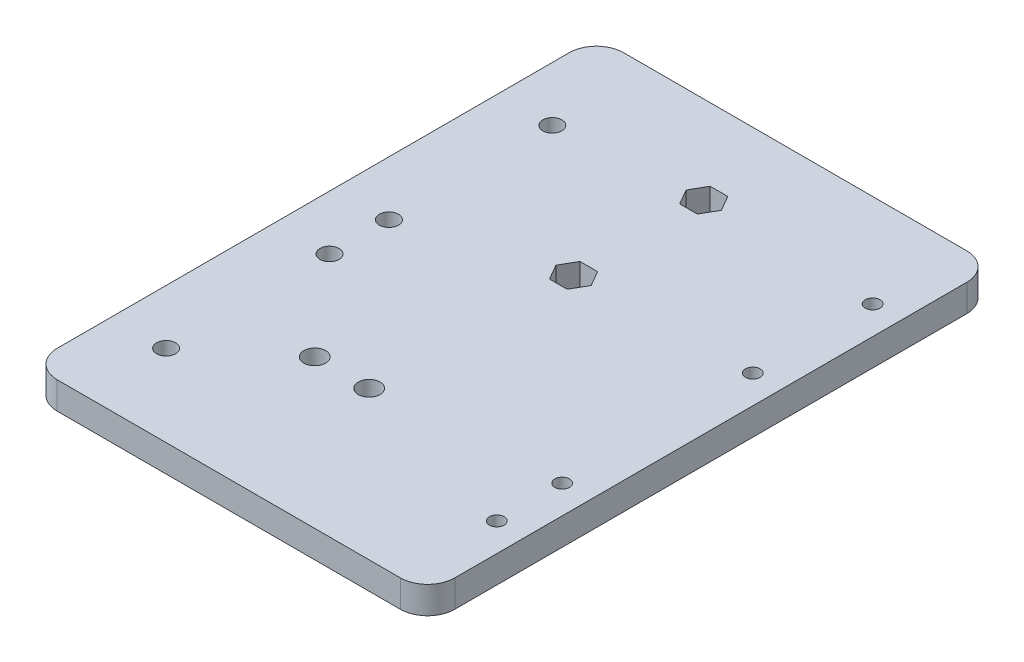
from build123d import *

# Parameters (mm, degrees)
SKETCH1_W           = 75
SKETCH1_H           = 104
BOSS_EXTRUDE1_DEPTH = 5
SKETCH2_R           = 1.75
CUT_EXTRUDE1_DEPTH  = 6
SKETCH3_R           = 1.35
SKETCH3_R_2         = 2
CUT_EXTRUDE2_DEPTH  = 6
SKETCH4_W           = 2
SKETCH4_H           = 104
CUT_EXTRUDE3_DEPTH  = 6
FILLET1_R           = 5


with BuildPart() as part:
    # Sketch1 → Boss-Extrude1 (new body)
    with BuildSketch(Plane(origin=(-157.38903018, 183.784554556, -475.424398782), x_dir=(1, 0, 0), z_dir=(0, 1, 0))):
        with Locations((37.5, 52)):
            Rectangle(SKETCH1_W, SKETCH1_H)
    extrude(amount=BOSS_EXTRUDE1_DEPTH)

    # Sketch2 → Cut-Extrude1 (cut, through all)
    with BuildSketch(Plane(origin=(0, 188.784554556, 0), x_dir=(1, 0, 0), z_dir=(0, 1, 0))):
        with Locations((-145.38903018, 490.424398782)):
            Circle(SKETCH2_R)
        with Locations((-145.38903018, 520.424398782)):
            Circle(SKETCH2_R)
        with Locations((-145.38903018, 531.324398782)):
            Circle(SKETCH2_R)
        with Locations((-145.38903018, 561.324398782)):
            Circle(SKETCH2_R)
    extrude(amount=-CUT_EXTRUDE1_DEPTH, mode=Mode.SUBTRACT)

    # Sketch3 → Cut-Extrude2 (cut, through all)
    with BuildSketch(Plane.XZ.offset(-183.784554556)):
        with Locations((-87.58903018, -493.330584132)):
            Circle(SKETCH3_R)
        with Locations((-87.58903018, -505.330584132)):
            Circle(SKETCH3_R)
        with Locations((-87.58903018, -540.330584132)):
            Circle(SKETCH3_R)
        with Locations((-87.589030179, -562.330584132)):
            Circle(SKETCH3_R)
        with Locations((-130.38903018, -502.700786837)):
            Circle(SKETCH3_R_2)
        with Locations((-120.38903018, -502.700786837)):
            Circle(SKETCH3_R_2)
        Polygon((-116.355868672, -563.330584132), (-117.972449426, -566.130584132), (-121.205610933, -566.130584132), (-122.822191687, -563.330584132), (-121.205610933, -560.530584132), (-117.972449426, -560.530584132), align=None)
        Polygon((-116.352707165, -539.423221972), (-117.969287918, -542.223221972), (-121.202449426, -542.223221972), (-122.81903018, -539.423221972), (-121.202449426, -536.623221972), (-117.969287918, -536.623221972), align=None)
    extrude(amount=-CUT_EXTRUDE2_DEPTH, mode=Mode.SUBTRACT)

    # Sketch4 → Cut-Extrude3 (cut, through all)
    with BuildSketch(Plane.XZ.offset(-183.784554556)):
        with Locations((-156.38903018, -527.424398782)):
            Rectangle(SKETCH4_W, SKETCH4_H)
    extrude(amount=-CUT_EXTRUDE3_DEPTH, mode=Mode.SUBTRACT)

    # Fillet1
    fillet1_edges = [part.edges().sort_by_distance(p)[0] for p in [
        (-155.38903018, 186.284554556, -475.424398782),
        (-155.38903018, 186.284554556, -579.424398782),
        (-82.38903018, 186.284554556, -579.424398782),
        (-82.38903018, 186.284554556, -475.424398782),
    ]]
    fillet(fillet1_edges, radius=FILLET1_R)


solid = part.part
